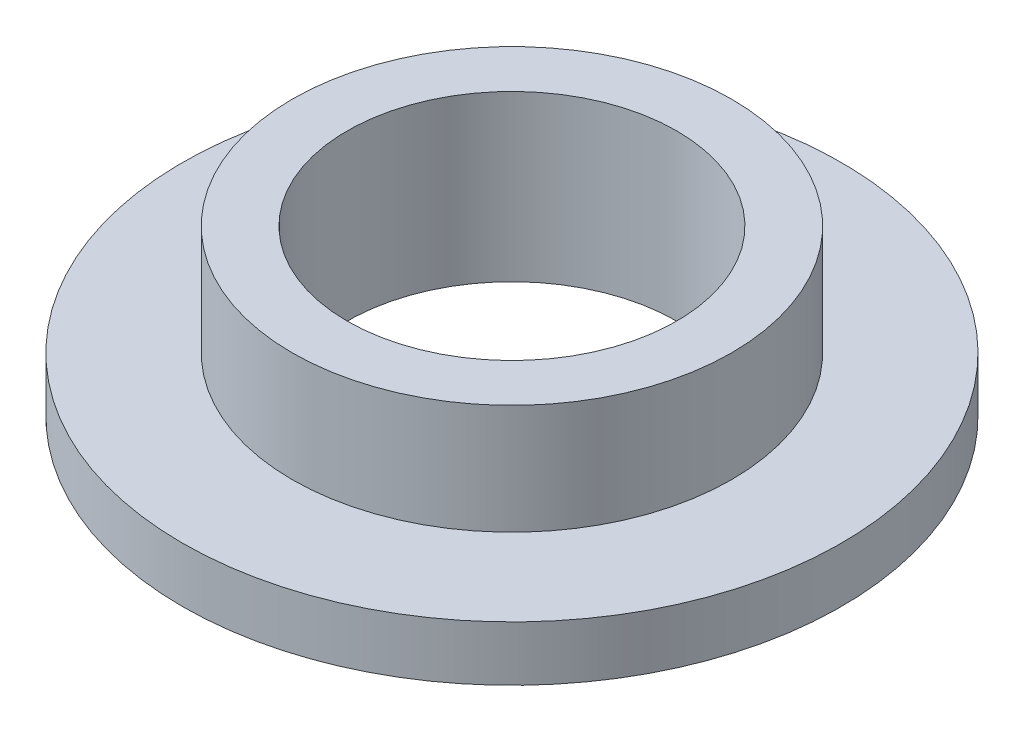
from build123d import *

# Parameters (mm, degrees)
SKETCH2_R           = 19.05
BOSS_EXTRUDE1_DEPTH = 3.175
SKETCH3_R           = 12.7
BOSS_EXTRUDE2_DEPTH = 6.35
SKETCH4_R           = 9.525
CUT_EXTRUDE1_DEPTH  = 10.525


with BuildPart() as part:
    # Sketch2 → Boss-Extrude1 (new body)
    with BuildSketch(Plane(origin=(0, 0, 0), x_dir=(1, 0, 0), z_dir=(0, 1, 0))):
        Circle(SKETCH2_R)
    extrude(amount=BOSS_EXTRUDE1_DEPTH)

    # Sketch3 → Boss-Extrude2 (add)
    with BuildSketch(Plane(origin=(0, 3.175, 0), x_dir=(1, 0, 0), z_dir=(0, 1, 0))):
        Circle(SKETCH3_R)
    extrude(amount=BOSS_EXTRUDE2_DEPTH)

    # Sketch4 → Cut-Extrude1 (cut, through all)
    with BuildSketch(Plane(origin=(0, 9.525, 0), x_dir=(1, 0, 0), z_dir=(0, 1, 0))):
        Circle(SKETCH4_R)
    extrude(amount=-CUT_EXTRUDE1_DEPTH, mode=Mode.SUBTRACT)


solid = part.part
